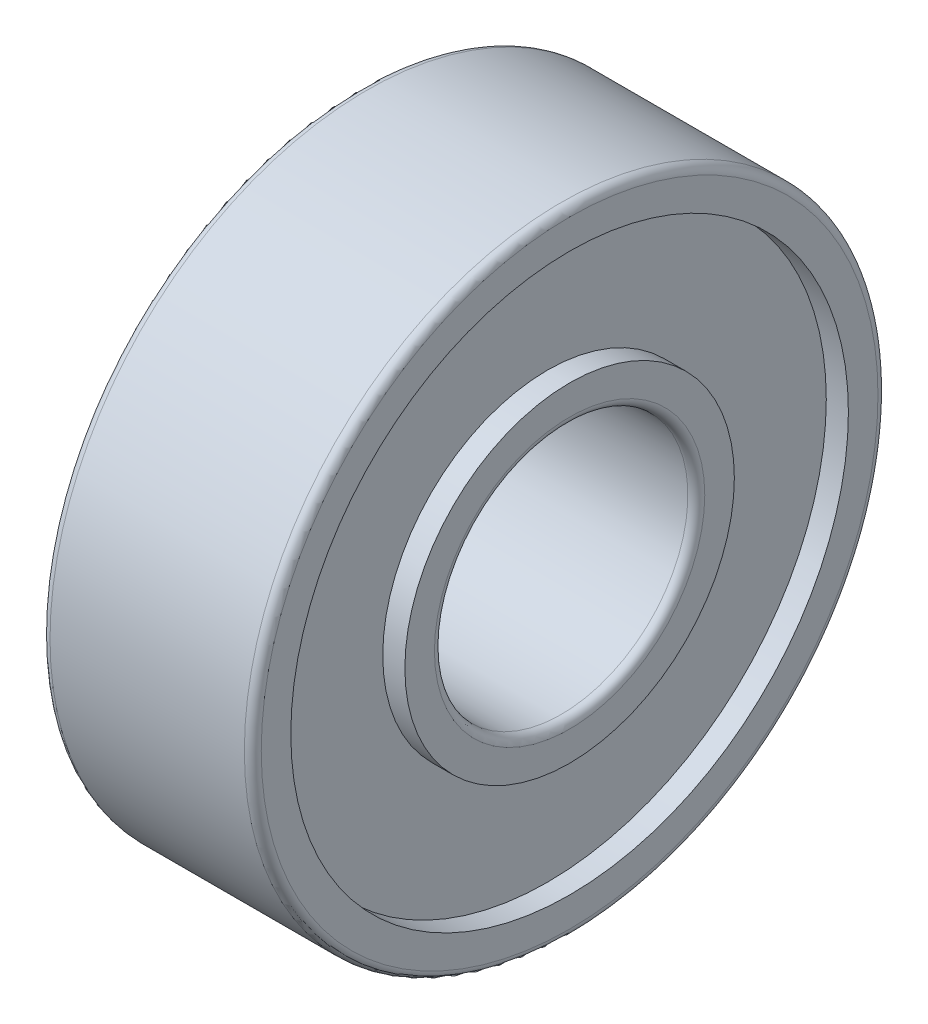
from build123d import *


with BuildPart() as part:
    # Sketch1 → Revolve1 (revolve)
    with BuildSketch(Plane.XY):
        with BuildLine():
            Line((0, 7.3), (0, 6.6))
            Line((0, 6.6), (0.5235, 6.6))
            Line((0.5235, 6.6), (0.5235, 3.9))
            Line((0.5235, 3.9), (0, 3.9))
            Line((0, 3.9), (0, 3.2))
            ThreePointArc((0, 3.2), (0.058578644, 3.058578644), (0.2, 3))
            Line((0.2, 3), (4.8, 3))
            ThreePointArc((4.8, 3), (4.941421356, 3.058578644), (5, 3.2))
            Line((5, 3.2), (5, 3.9))
            Line((5, 3.9), (4.4765, 3.9))
            Line((4.4765, 3.9), (4.4765, 6.6))
            Line((4.4765, 6.6), (5, 6.6))
            Line((5, 6.6), (5, 7.3))
            ThreePointArc((5, 7.3), (4.941421356, 7.441421356), (4.8, 7.5))
            Line((4.8, 7.5), (0.2, 7.5))
            ThreePointArc((0.2, 7.5), (0.058578644, 7.441421356), (0, 7.3))
        make_face()
    revolve(axis=Axis((4.8, 0, 0), (-1, 0, 0)))


solid = part.part
